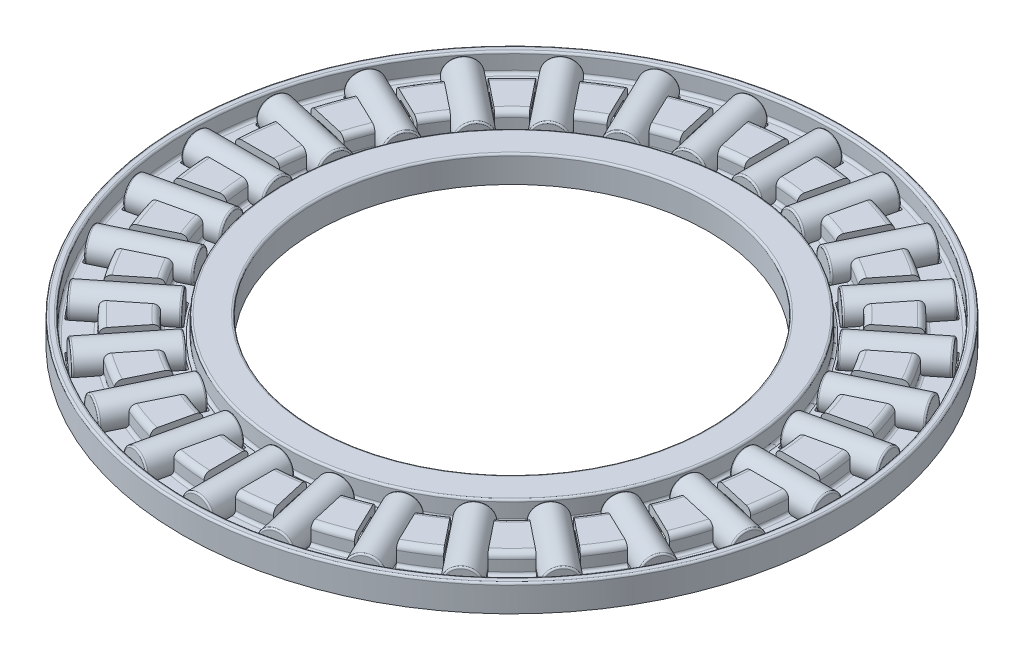
from build123d import *

# Parameters (mm, degrees)
FILLET1_R                = 0.369230769
FILLET2_R                = 0.369230769
FILLET3_R                = 0.125
FILLET4_R                = 0.184615385
CUT_EXTRUDE1_DEPTH       = 30.71064624
FILLET5_R                = 0.100040891
CIRPATTERN1_COUNT        = 28
FILLET5_OF_CIRPATTERN1_R = 0.100040891
SKETCH5_W                = 5.206964144
SKETCH5_H                = 1
FILLET6_R                = 0.100040891
CIRPATTERN2_COUNT        = 28


with BuildPart() as part:
    # Sketch3 → Revolve1 (revolve)
    with BuildSketch(Plane(origin=(0, 0, 0), x_dir=(0, 0, -1), z_dir=(1, 0, 0))):
        Polygon((13.18, -0.85), (13.18, 0.372564103), (13.84, 0.372564103), (13.84, -0.85), (16.33025641, -0.85), (16.33025641, 0.372564103), (18.176410256, 0.372564103), (18.176410256, -0.85), (20.666666667, -0.85), (20.666666667, 0.372564103), (20.833333333, 0.372564103), (20.833333333, -0.85), (21, -0.85), (21, 0.85), (20.5, 0.85), (20.5, -0.372564103), (18.653846154, -0.372564103), (18.653846154, 0.85), (15.852820513, 0.85), (15.852820513, -0.372564103), (14.5, -0.372564103), (14.5, 0.85), (12.52, 0.85), (12.52, -0.85), align=None)
    revolve(axis=Axis((0, 1, 0), (0, -1, 0)))

    # Fillet1
    fillet1_edges = [part.edges().sort_by_distance(p)[0] for p in [
        (0, -0.85, 18.176410256),
        (0, -0.85, 20.666666667),
        (0, -0.85, 13.84),
        (0, -0.85, 16.33025641),
    ]]
    fillet(fillet1_edges, radius=FILLET1_R)

    # Fillet2
    fillet2_edges = [part.edges().sort_by_distance(p)[0] for p in [
        (0, 0.85, 18.653846154),
        (0, 0.85, 15.852820513),
    ]]
    fillet(fillet2_edges, radius=FILLET2_R)

    # Fillet3
    fillet3_edges = [part.edges().sort_by_distance(p)[0] for p in [
        (0, 0.85, 20.5),
        (0, 0.85, 21),
        (0, 0.85, 14.5),
        (0, 0.85, 12.52),
    ]]
    fillet(fillet3_edges, radius=FILLET3_R)

    # Fillet4
    fillet4_edges = [part.edges().sort_by_distance(p)[0] for p in [
        (0, 0.372564103, 16.33025641),
        (0, 0.372564103, 18.176410256),
        (0, -0.372564103, 20.5),
        (0, -0.372564103, 18.653846154),
        (0, -0.372564103, 15.852820513),
        (0, -0.372564103, 14.5),
    ]]
    fillet(fillet4_edges, radius=FILLET4_R)

    # Sketch4 → Cut-Extrude1 (cut, symmetric)
    with BuildSketch(Plane(origin=(0, 0, 0), x_dir=(1, 0, 0), z_dir=(0, 1, 0))):
        with BuildLine():
            Line((14.766177569, 1), (20.175232341, 1))
            ThreePointArc((20.175232341, 1), (20.2, 0), (20.175232341, -1))
            Line((20.175232341, -1), (14.766177569, -1))
            ThreePointArc((14.766177569, -1), (14.8, 0), (14.766177569, 1))
        make_face()
    cut_extrude1 = extrude(amount=CUT_EXTRUDE1_DEPTH, both=True, mode=Mode.SUBTRACT)

    # Fillet5
    fillet5_edges = [part.edges().sort_by_distance(p)[0] for p in [
        (20.175232341, -0.611282051, -1),
        (20.175232341, -0.611282051, 1),
        (14.766177569, -0.611282051, -1),
        (14.766177569, -0.611282051, 1),
    ]]
    fillet(fillet5_edges, radius=FILLET5_R)

    # CirPattern1: Cut-Extrude1 ×28 about axis
    cirpattern1_axis = Axis((0, 1, 0), (0, -1, 0))
    for i in range(1, CIRPATTERN1_COUNT):
        add(cut_extrude1.rotate(cirpattern1_axis, i * 360 / CIRPATTERN1_COUNT), mode=Mode.SUBTRACT)

    # Fillet5 of CirPattern1
    fillet5_of_cirpattern1_edges = [part.edges().sort_by_distance(p)[0] for p in [
        (19.891918078, -0.611282051, 3.514483631),
        (19.44687621, -0.611282051, 5.464339455),
        (14.618479602, -0.611282051, 2.310855711),
        (14.173437734, -0.611282051, 4.260711536),
        (18.611139981, -0.611282051, 7.852736378),
        (17.743372503, -0.611282051, 9.654674113),
        (13.737750027, -0.611282051, 5.505835468),
        (12.869982548, -0.611282051, 7.307773204),
        (16.397121612, -0.611282051, 11.797220132),
        (15.150142008, -0.611282051, 13.360883097),
        (12.168152301, -0.611282051, 8.424729644),
        (10.921172697, -0.611282051, 9.988392609),
        (13.360883097, -0.611282051, 15.150142008),
        (11.797220132, -0.611282051, 16.397121612),
        (9.988392609, -0.611282051, 10.921172697),
        (8.424729644, -0.611282051, 12.168152301),
        (9.654674113, -0.611282051, 17.743372503),
        (7.852736378, -0.611282051, 18.611139981),
        (7.307773204, -0.611282051, 12.869982548),
        (5.505835468, -0.611282051, 13.737750027),
        (5.464339455, -0.611282051, 19.44687621),
        (3.514483631, -0.611282051, 19.891918078),
        (4.260711536, -0.611282051, 14.173437734),
        (2.310855711, -0.611282051, 14.618479602),
        (1, -0.611282051, 20.175232341),
        (-1, -0.611282051, 20.175232341),
        (1, -0.611282051, 14.766177569),
        (-1, -0.611282051, 14.766177569),
        (-3.514483631, -0.611282051, 19.891918078),
        (-5.464339455, -0.611282051, 19.44687621),
        (-2.310855711, -0.611282051, 14.618479602),
        (-4.260711536, -0.611282051, 14.173437734),
        (-7.852736378, -0.611282051, 18.611139981),
        (-9.654674113, -0.611282051, 17.743372503),
        (-5.505835468, -0.611282051, 13.737750027),
        (-7.307773204, -0.611282051, 12.869982548),
        (-11.797220132, -0.611282051, 16.397121612),
        (-13.360883097, -0.611282051, 15.150142008),
        (-8.424729644, -0.611282051, 12.168152301),
        (-9.988392609, -0.611282051, 10.921172697),
        (-15.150142008, -0.611282051, 13.360883097),
        (-16.397121612, -0.611282051, 11.797220132),
        (-10.921172697, -0.611282051, 9.988392609),
        (-12.168152301, -0.611282051, 8.424729644),
        (-17.743372503, -0.611282051, 9.654674113),
        (-18.611139981, -0.611282051, 7.852736378),
        (-12.869982548, -0.611282051, 7.307773204),
        (-13.737750027, -0.611282051, 5.505835468),
        (-19.44687621, -0.611282051, 5.464339455),
        (-19.891918078, -0.611282051, 3.514483631),
        (-14.173437734, -0.611282051, 4.260711536),
        (-14.618479602, -0.611282051, 2.310855711),
        (-20.175232341, -0.611282051, 1),
        (-20.175232341, -0.611282051, -1),
        (-14.766177569, -0.611282051, 1),
        (-14.766177569, -0.611282051, -1),
        (-19.891918078, -0.611282051, -3.514483631),
        (-19.44687621, -0.611282051, -5.464339455),
        (-14.618479602, -0.611282051, -2.310855711),
        (-14.173437734, -0.611282051, -4.260711536),
        (-18.611139981, -0.611282051, -7.852736378),
        (-17.743372503, -0.611282051, -9.654674113),
        (-13.737750027, -0.611282051, -5.505835468),
        (-12.869982548, -0.611282051, -7.307773204),
        (-16.397121612, -0.611282051, -11.797220132),
        (-15.150142008, -0.611282051, -13.360883097),
        (-12.168152301, -0.611282051, -8.424729644),
        (-10.921172697, -0.611282051, -9.988392609),
        (-13.360883097, -0.611282051, -15.150142008),
        (-11.797220132, -0.611282051, -16.397121612),
        (-9.988392609, -0.611282051, -10.921172697),
        (-8.424729644, -0.611282051, -12.168152301),
        (-9.654674113, -0.611282051, -17.743372503),
        (-7.852736378, -0.611282051, -18.611139981),
        (-7.307773204, -0.611282051, -12.869982548),
        (-5.505835468, -0.611282051, -13.737750027),
        (-5.464339455, -0.611282051, -19.44687621),
        (-3.514483631, -0.611282051, -19.891918078),
        (-4.260711536, -0.611282051, -14.173437734),
        (-2.310855711, -0.611282051, -14.618479602),
        (-1, -0.611282051, -20.175232341),
        (1, -0.611282051, -20.175232341),
        (-1, -0.611282051, -14.766177569),
        (1, -0.611282051, -14.766177569),
        (3.514483631, -0.611282051, -19.891918078),
        (5.464339455, -0.611282051, -19.44687621),
        (2.310855711, -0.611282051, -14.618479602),
        (4.260711536, -0.611282051, -14.173437734),
        (7.852736378, -0.611282051, -18.611139981),
        (9.654674113, -0.611282051, -17.743372503),
        (5.505835468, -0.611282051, -13.737750027),
        (7.307773204, -0.611282051, -12.869982548),
        (11.797220132, -0.611282051, -16.397121612),
        (13.360883097, -0.611282051, -15.150142008),
        (8.424729644, -0.611282051, -12.168152301),
        (9.988392609, -0.611282051, -10.921172697),
        (15.150142008, -0.611282051, -13.360883097),
        (16.397121612, -0.611282051, -11.797220132),
        (10.921172697, -0.611282051, -9.988392609),
        (12.168152301, -0.611282051, -8.424729644),
        (17.743372503, -0.611282051, -9.654674113),
        (18.611139981, -0.611282051, -7.852736378),
        (12.869982548, -0.611282051, -7.307773204),
        (13.737750027, -0.611282051, -5.505835468),
        (19.44687621, -0.611282051, -5.464339455),
        (19.891918078, -0.611282051, -3.514483631),
        (14.173437734, -0.611282051, -4.260711536),
        (14.618479602, -0.611282051, -2.310855711),
    ]]
    fillet(fillet5_of_cirpattern1_edges, radius=FILLET5_OF_CIRPATTERN1_R)


with BuildPart() as body_2:
    # Sketch5 → Revolve2 (revolve)
    with BuildSketch(Plane(origin=(0, 0, 0), x_dir=(1, 0, 0), z_dir=(0, 1, 0))):
        with Locations((17.476319466, 0.5)):
            Rectangle(SKETCH5_W, SKETCH5_H)
    revolve(axis=Axis((20.2, 0, 0), (-1, 0, 0)))

    # Fillet6
    fillet6_edges = [body_2.edges().sort_by_distance(p)[0] for p in [
        (14.872837394, 0, 1),
        (20.079801538, 0, 1),
    ]]
    fillet(fillet6_edges, radius=FILLET6_R)


with BuildPart() as cirpattern2_1:
    # CirPattern2: pattern copy
    add(body_2.part.rotate(Axis((0, 1, 0), (0, -1, 0)), 1 * 360 / CIRPATTERN2_COUNT))


with BuildPart() as cirpattern2_2:
    # CirPattern2: pattern copy
    add(body_2.part.rotate(Axis((0, 1, 0), (0, -1, 0)), 2 * 360 / CIRPATTERN2_COUNT))


with BuildPart() as cirpattern2_3:
    # CirPattern2: pattern copy
    add(body_2.part.rotate(Axis((0, 1, 0), (0, -1, 0)), 3 * 360 / CIRPATTERN2_COUNT))


with BuildPart() as cirpattern2_4:
    # CirPattern2: pattern copy
    add(body_2.part.rotate(Axis((0, 1, 0), (0, -1, 0)), 4 * 360 / CIRPATTERN2_COUNT))


with BuildPart() as cirpattern2_5:
    # CirPattern2: pattern copy
    add(body_2.part.rotate(Axis((0, 1, 0), (0, -1, 0)), 5 * 360 / CIRPATTERN2_COUNT))


with BuildPart() as cirpattern2_6:
    # CirPattern2: pattern copy
    add(body_2.part.rotate(Axis((0, 1, 0), (0, -1, 0)), 6 * 360 / CIRPATTERN2_COUNT))


with BuildPart() as cirpattern2_7:
    # CirPattern2: pattern copy
    add(body_2.part.rotate(Axis((0, 1, 0), (0, -1, 0)), 7 * 360 / CIRPATTERN2_COUNT))


with BuildPart() as cirpattern2_8:
    # CirPattern2: pattern copy
    add(body_2.part.rotate(Axis((0, 1, 0), (0, -1, 0)), 8 * 360 / CIRPATTERN2_COUNT))


with BuildPart() as cirpattern2_9:
    # CirPattern2: pattern copy
    add(body_2.part.rotate(Axis((0, 1, 0), (0, -1, 0)), 9 * 360 / CIRPATTERN2_COUNT))


with BuildPart() as cirpattern2_10:
    # CirPattern2: pattern copy
    add(body_2.part.rotate(Axis((0, 1, 0), (0, -1, 0)), 10 * 360 / CIRPATTERN2_COUNT))


with BuildPart() as cirpattern2_11:
    # CirPattern2: pattern copy
    add(body_2.part.rotate(Axis((0, 1, 0), (0, -1, 0)), 11 * 360 / CIRPATTERN2_COUNT))


with BuildPart() as cirpattern2_12:
    # CirPattern2: pattern copy
    add(body_2.part.rotate(Axis((0, 1, 0), (0, -1, 0)), 12 * 360 / CIRPATTERN2_COUNT))


with BuildPart() as cirpattern2_13:
    # CirPattern2: pattern copy
    add(body_2.part.rotate(Axis((0, 1, 0), (0, -1, 0)), 13 * 360 / CIRPATTERN2_COUNT))


with BuildPart() as cirpattern2_14:
    # CirPattern2: pattern copy
    add(body_2.part.rotate(Axis((0, 1, 0), (0, -1, 0)), 14 * 360 / CIRPATTERN2_COUNT))


with BuildPart() as cirpattern2_15:
    # CirPattern2: pattern copy
    add(body_2.part.rotate(Axis((0, 1, 0), (0, -1, 0)), 15 * 360 / CIRPATTERN2_COUNT))


with BuildPart() as cirpattern2_16:
    # CirPattern2: pattern copy
    add(body_2.part.rotate(Axis((0, 1, 0), (0, -1, 0)), 16 * 360 / CIRPATTERN2_COUNT))


with BuildPart() as cirpattern2_17:
    # CirPattern2: pattern copy
    add(body_2.part.rotate(Axis((0, 1, 0), (0, -1, 0)), 17 * 360 / CIRPATTERN2_COUNT))


with BuildPart() as cirpattern2_18:
    # CirPattern2: pattern copy
    add(body_2.part.rotate(Axis((0, 1, 0), (0, -1, 0)), 18 * 360 / CIRPATTERN2_COUNT))


with BuildPart() as cirpattern2_19:
    # CirPattern2: pattern copy
    add(body_2.part.rotate(Axis((0, 1, 0), (0, -1, 0)), 19 * 360 / CIRPATTERN2_COUNT))


with BuildPart() as cirpattern2_20:
    # CirPattern2: pattern copy
    add(body_2.part.rotate(Axis((0, 1, 0), (0, -1, 0)), 20 * 360 / CIRPATTERN2_COUNT))


with BuildPart() as cirpattern2_21:
    # CirPattern2: pattern copy
    add(body_2.part.rotate(Axis((0, 1, 0), (0, -1, 0)), 21 * 360 / CIRPATTERN2_COUNT))


with BuildPart() as cirpattern2_22:
    # CirPattern2: pattern copy
    add(body_2.part.rotate(Axis((0, 1, 0), (0, -1, 0)), 22 * 360 / CIRPATTERN2_COUNT))


with BuildPart() as cirpattern2_23:
    # CirPattern2: pattern copy
    add(body_2.part.rotate(Axis((0, 1, 0), (0, -1, 0)), 23 * 360 / CIRPATTERN2_COUNT))


with BuildPart() as cirpattern2_24:
    # CirPattern2: pattern copy
    add(body_2.part.rotate(Axis((0, 1, 0), (0, -1, 0)), 24 * 360 / CIRPATTERN2_COUNT))


with BuildPart() as cirpattern2_25:
    # CirPattern2: pattern copy
    add(body_2.part.rotate(Axis((0, 1, 0), (0, -1, 0)), 25 * 360 / CIRPATTERN2_COUNT))


with BuildPart() as cirpattern2_26:
    # CirPattern2: pattern copy
    add(body_2.part.rotate(Axis((0, 1, 0), (0, -1, 0)), 26 * 360 / CIRPATTERN2_COUNT))


with BuildPart() as cirpattern2_27:
    # CirPattern2: pattern copy
    add(body_2.part.rotate(Axis((0, 1, 0), (0, -1, 0)), 27 * 360 / CIRPATTERN2_COUNT))


solid = Compound([part.part, body_2.part, cirpattern2_1.part, cirpattern2_2.part, cirpattern2_3.part, cirpattern2_4.part, cirpattern2_5.part, cirpattern2_6.part, cirpattern2_7.part, cirpattern2_8.part, cirpattern2_9.part, cirpattern2_10.part, cirpattern2_11.part, cirpattern2_12.part, cirpattern2_13.part, cirpattern2_14.part, cirpattern2_15.part, cirpattern2_16.part, cirpattern2_17.part, cirpattern2_18.part, cirpattern2_19.part, cirpattern2_20.part, cirpattern2_21.part, cirpattern2_22.part, cirpattern2_23.part, cirpattern2_24.part, cirpattern2_25.part, cirpattern2_26.part, cirpattern2_27.part])
